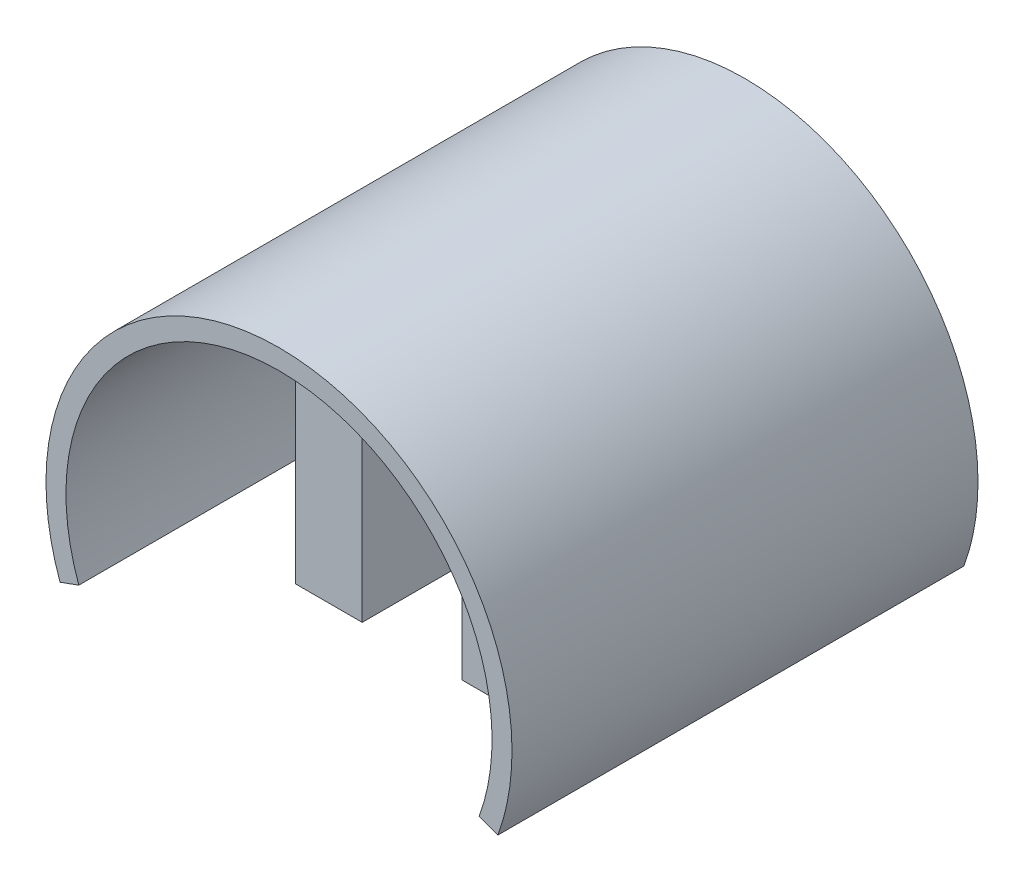
from build123d import *

# Parameters (mm, degrees)
ESQUISSE1_R                  = 35
ESQUISSE1_R_2                = 32
BOSS_EXTRU_1_DEPTH           = 70
BOSS_EXTRU_2_DEPTH           = 70
ESQUISSE3_R                  = 3.2
ENL_V_MAT_EXTRU_1_DEPTH      = 20
ENL_V_MAT_EXTRU_1_DEPTH_BACK = 20
ESQUISSE5_W                  = 100
ESQUISSE5_H                  = 50
ENL_V_MAT_EXTRU_3_DEPTH      = 71
ESQUISSE7_W                  = 10
ESQUISSE7_H                  = 70
ESQUISSE7_R                  = 3.2
BOSS_EXTRU_3_DEPTH           = 8
BOSS_EXTRU_5_DEPTH           = 70
ESQUISSE10_R                 = 32
ENL_V_MAT_EXTRU_4_DEPTH      = 20
CONG_2_R                     = 2
BOSS_EXTRU_6_START           = -1.5
ESQUISSE11_R                 = 3.2
BOSS_EXTRU_6_DEPTH           = 33


with BuildPart() as part:
    # Esquisse1 → Boss.-Extru.1 (new body)
    with BuildSketch(Plane.XY):
        Circle(ESQUISSE1_R)
        Circle(ESQUISSE1_R_2, mode=Mode.SUBTRACT)
    extrude(amount=BOSS_EXTRU_1_DEPTH)

    # Esquisse2 → Boss.-Extru.2 (add)
    with BuildSketch(Plane.XY.offset(70)):
        with BuildLine():
            Line((-7.5, 31.108680461), (-7.5, -31.108680461))
            ThreePointArc((-7.5, -31.108680461), (-12.685066047, -29.378378093), (-17.5, -26.790856649))
            Line((-17.5, -26.790856649), (-17.5, 26.790856649))
            ThreePointArc((-17.5, 26.790856649), (-12.685066047, 29.378378093), (-7.5, 31.108680461))
        make_face()
        with BuildLine():
            Line((17.5, -26.790856649), (17.5, 26.790856649))
            ThreePointArc((17.5, 26.790856649), (12.685066047, 29.378378093), (7.5, 31.108680461))
            Line((7.5, 31.108680461), (7.5, -31.108680461))
            ThreePointArc((7.5, -31.108680461), (12.685066047, -29.378378093), (17.5, -26.790856649))
        make_face()
    extrude(amount=-BOSS_EXTRU_2_DEPTH)

    # Esquisse3 → Enl_v. mat.-Extru.1 (cut, two sides)
    with BuildSketch(Plane(origin=(0, 0, 0), x_dir=(1, 0, 0), z_dir=(0, 1, 0))) as enl_v_mat_extru_1_sk:
        with Locations((-12.5, -10)):
            Circle(ESQUISSE3_R)
        with Locations((-12.5, -40)):
            Circle(ESQUISSE3_R)
        with Locations((12.5, -40)):
            Circle(ESQUISSE3_R)
        with Locations((12.5, -10)):
            Circle(ESQUISSE3_R)
    extrude(amount=ENL_V_MAT_EXTRU_1_DEPTH, mode=Mode.SUBTRACT)
    extrude(enl_v_mat_extru_1_sk.sketch, amount=-ENL_V_MAT_EXTRU_1_DEPTH_BACK, mode=Mode.SUBTRACT)

    # Esquisse5 → Enl_v. mat.-Extru.3 (cut, through all)
    with BuildSketch(Plane.XY.offset(70)):
        with Locations((0, -31.5)):
            Rectangle(ESQUISSE5_W, ESQUISSE5_H)
    extrude(amount=-ENL_V_MAT_EXTRU_3_DEPTH, mode=Mode.SUBTRACT)

    # Esquisse7 → Boss.-Extru.3 (add)
    with BuildSketch(Plane.XZ.offset(6.5)):
        with Locations((-12.5, 35)):
            Rectangle(ESQUISSE7_W, ESQUISSE7_H)
        with Locations((-12.5, 40)):
            Circle(ESQUISSE7_R, mode=Mode.SUBTRACT)
        with Locations((-12.5, 10)):
            Circle(ESQUISSE7_R, mode=Mode.SUBTRACT)
        with Locations((12.5, 35)):
            Rectangle(ESQUISSE7_W, ESQUISSE7_H)
        with Locations((12.5, 40)):
            Circle(ESQUISSE7_R, mode=Mode.SUBTRACT)
        with Locations((12.5, 10)):
            Circle(ESQUISSE7_R, mode=Mode.SUBTRACT)
    extrude(amount=BOSS_EXTRU_3_DEPTH)

    # Esquisse8 → Boss.-Extru.5 (add)
    with BuildSketch(Plane.XY.offset(70)):
        with BuildLine():
            Line((32.889241728, -11.970705016), (30.070163865, -10.944644586))
            ThreePointArc((30.070163865, -10.944644586), (30.781853005, -8.745142969), (31.332890068, -6.5))
            Line((31.332890068, -6.5), (34.391132578, -6.5))
            ThreePointArc((34.391132578, -6.5), (33.751212497, -9.265832665), (32.889241728, -11.970705016))
        make_face()
        with BuildLine():
            Line((-32.889241728, -11.970705016), (-30.070163865, -10.944644586))
            ThreePointArc((-30.070163865, -10.944644586), (-30.781853005, -8.745142969), (-31.332890068, -6.5))
            Line((-31.332890068, -6.5), (-34.391132578, -6.5))
            ThreePointArc((-34.391132578, -6.5), (-33.751212497, -9.265832665), (-32.889241728, -11.970705016))
        make_face()
    extrude(amount=-BOSS_EXTRU_5_DEPTH)

    # Esquisse10 → Enl_v. mat.-Extru.4 (cut)
    with BuildSketch(Plane.XY.offset(70)):
        Circle(ESQUISSE10_R)
    extrude(amount=-ENL_V_MAT_EXTRU_4_DEPTH, mode=Mode.SUBTRACT)

    # Cong_2
    cong_2_edges = [part.edges().sort_by_distance(p)[0] for p in [
        (-17.5, 26.790856649, 25),
        (-7.5, 31.108680461, 25),
        (7.5, 31.108680461, 25),
        (17.5, 26.790856649, 25),
    ]]
    fillet(cong_2_edges, radius=CONG_2_R)

    # Esquisse11 → Boss.-Extru.6 (add)
    with BuildSketch(Plane.XZ.offset(14.5).offset(BOSS_EXTRU_6_START)):
        with Locations((12.5, 10)):
            Circle(ESQUISSE11_R)
        with Locations((12.5, 40)):
            Circle(ESQUISSE11_R)
        with Locations((-12.5, 40)):
            Circle(ESQUISSE11_R)
        with Locations((-12.5, 10)):
            Circle(ESQUISSE11_R)
    extrude(amount=-BOSS_EXTRU_6_DEPTH)


solid = part.part
